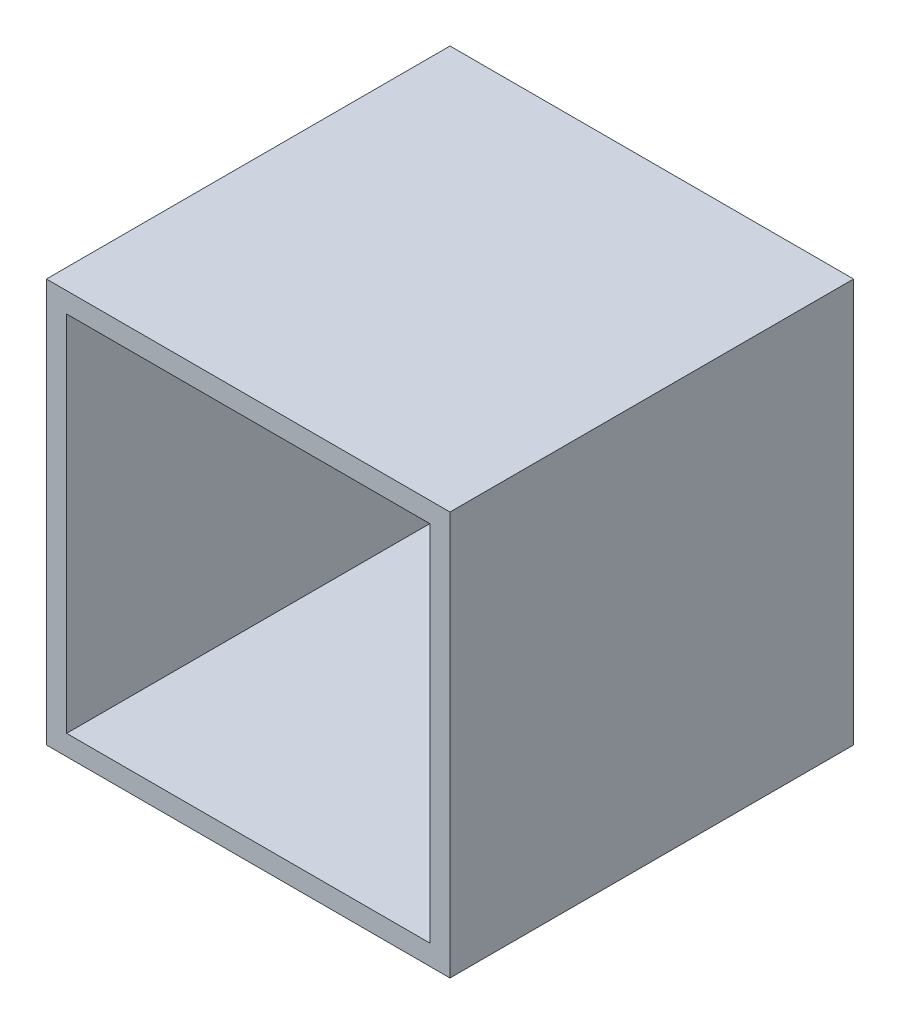
from build123d import *

# Parameters (mm, degrees)
SKETCH1_W           = 100
SKETCH1_H           = 100
BOSS_EXTRUDE1_DEPTH = 100
SHELL1_T            = -5


with BuildPart() as part:
    # Sketch1 → Boss-Extrude1 (new body)
    with BuildSketch(Plane.XY):
        with Locations((-5.898502638, -36.295960273)):
            Rectangle(SKETCH1_W, SKETCH1_H)
    extrude(amount=BOSS_EXTRUDE1_DEPTH)

    # Shell1
    shell1_openings = [part.faces().sort_by_distance(p)[0] for p in [
        (-5.898502638, -36.295960273, 100),
    ]]
    offset(amount=SHELL1_T, openings=shell1_openings, kind=Kind.INTERSECTION)


solid = part.part
